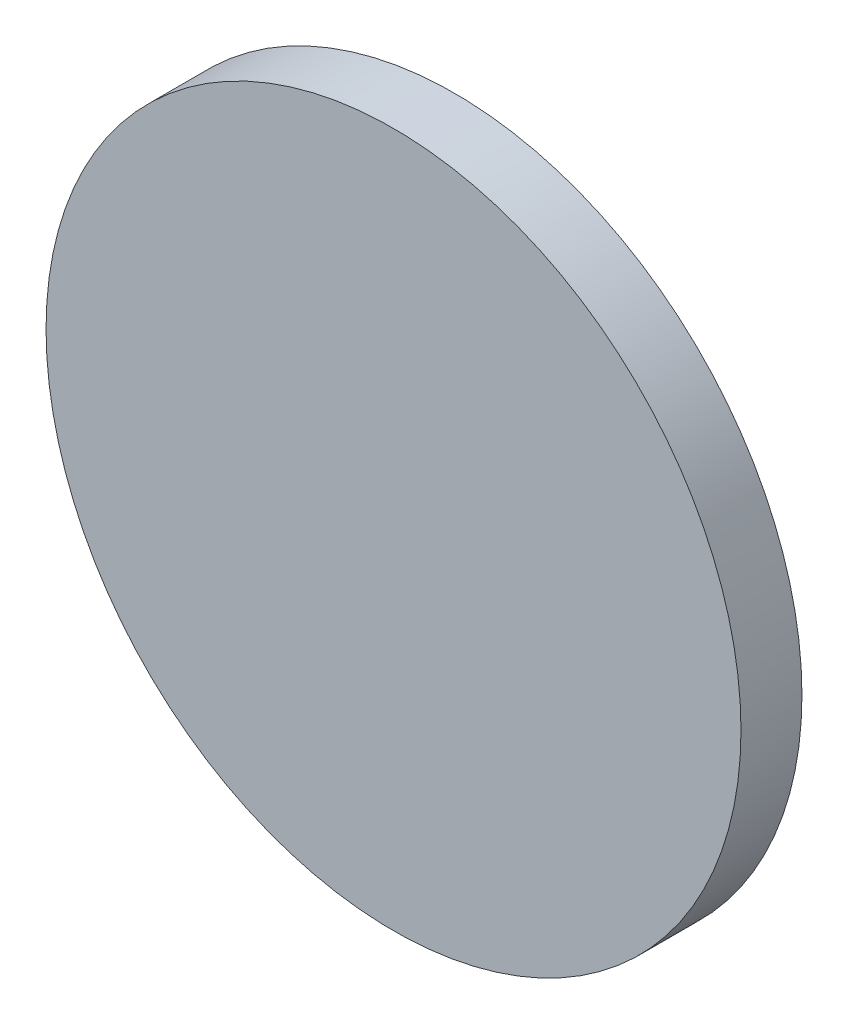
from build123d import *

# Parameters (mm, degrees)
SKETCH1_R           = 56.993236011
BOSS_EXTRUDE1_DEPTH = 10


with BuildPart() as part:
    # Sketch1 → Boss-Extrude1 (new body)
    with BuildSketch(Plane.XY):
        Circle(SKETCH1_R)
    extrude(amount=BOSS_EXTRUDE1_DEPTH)


solid = part.part
